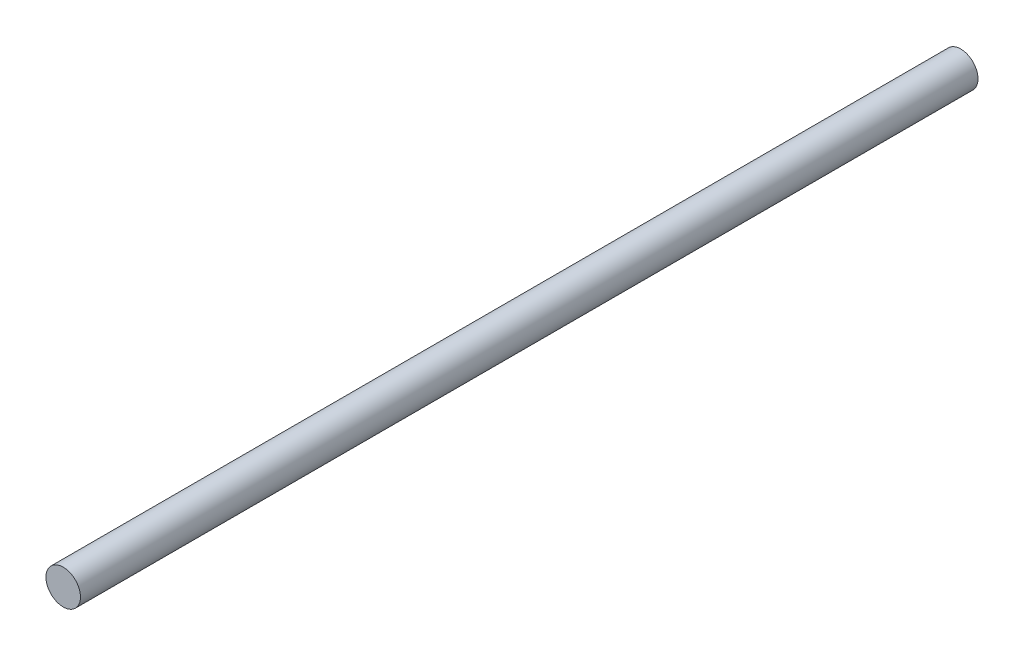
from build123d import *

# Parameters (mm, degrees)
BOSS_EXTRUDE1_DEPTH      = 130
BOSS_EXTRUDE1_DEPTH_BACK = 130
SKETCH1_R                = 5


with BuildPart() as part:
    # Sketch1 → Boss-Extrude1 (new, two sides: drawn at the far end of the back side and taken through both)
    with BuildSketch(Plane.XY.offset(-BOSS_EXTRUDE1_DEPTH_BACK)):
        Circle(SKETCH1_R)
    extrude(amount=BOSS_EXTRUDE1_DEPTH + BOSS_EXTRUDE1_DEPTH_BACK)


solid = part.part
